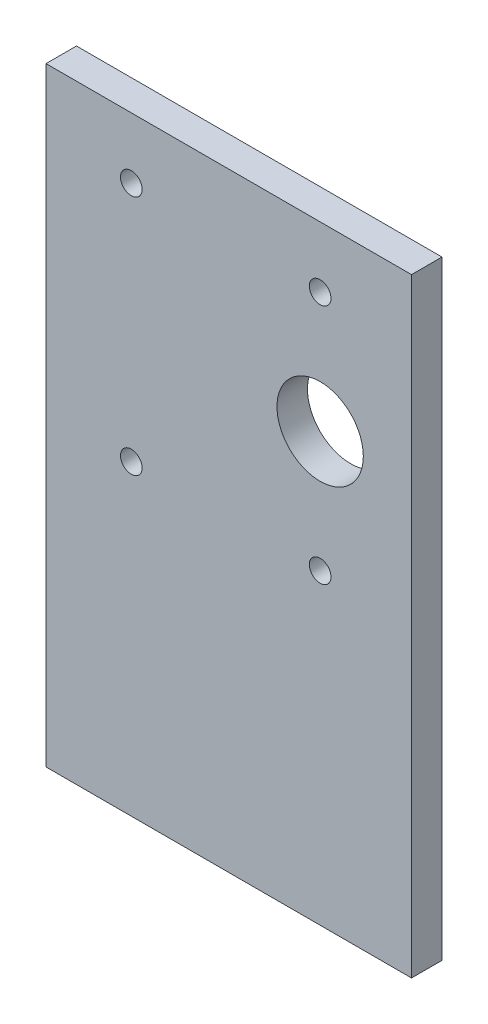
from build123d import *

# Parameters (mm, degrees)
SKETCH1_W               = 38.1
SKETCH1_H               = 63.5
BOSS_EXTRUDE1_DEPTH     = 3.175
F_4_40_TAPPED_HOLE1_D   = 2.2606
SKETCH3_R               = 4.5
M8_CLEARANCE_HOLE_DEPTH = 3.175


with BuildPart() as part:
    # Sketch1 → Boss-Extrude1 (new body)
    with BuildSketch(Plane.XY):
        with Locations((19.05, 31.75)):
            Rectangle(SKETCH1_W, SKETCH1_H)
    extrude(amount=BOSS_EXTRUDE1_DEPTH)

    # #4-40 Tapped Hole1 (through all)
    with Locations(Plane(origin=(28.575, 57.15, 3.175), x_dir=(1, 0, 0), z_dir=(0, 0, 1))):
        with Locations((0, 0), (0, -25.146), (-19.685, -25.146), (-19.685, 0)):
            Hole(F_4_40_TAPPED_HOLE1_D / 2)

    # Sketch3 → M8 clearance hole (cut)
    with BuildSketch(Plane.XY.offset(3.175)):
        with Locations((28.575, 44.577)):
            Circle(SKETCH3_R)
    extrude(amount=-M8_CLEARANCE_HOLE_DEPTH, mode=Mode.SUBTRACT)


solid = part.part
